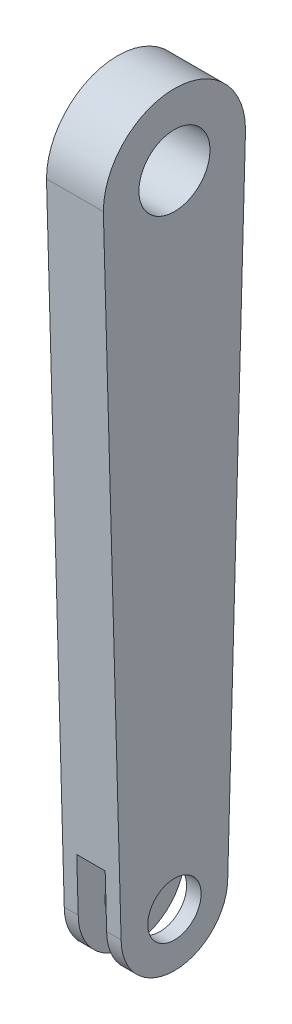
from build123d import *

# Parameters (mm, degrees)
EXTRUDE_1_DEPTH     = 16
SKETCH_2_R          = 10
SKETCH_2_R_2        = 7.5
CUT_EXTRUDE_1_DEPTH = 16
SKETCH_3_W          = 8
SKETCH_3_H          = 40
CUT_EXTRUDE_2_DEPTH = 65


with BuildPart() as part:
    # 草图1 → 凸台-拉伸1 (new body)
    with BuildSketch(Plane(origin=(0, 0, 0), x_dir=(0, 0, -1), z_dir=(1, 0, 0))):
        with BuildLine():
            ThreePointArc((20, 0), (0, 20), (-20, 0))
            Line((-20, 0), (-15, -180))
            ThreePointArc((-15, -180), (0, -195), (15, -180))
            Line((15, -180), (20, 0))
        make_face()
    extrude(amount=EXTRUDE_1_DEPTH)

    # 草图2 → 切除-拉伸1 (cut)
    with BuildSketch(Plane(origin=(16, 0, 0), x_dir=(0, 0, -1), z_dir=(1, 0, 0))):
        Circle(SKETCH_2_R)
        with Locations((0, -180)):
            Circle(SKETCH_2_R_2)
    extrude(amount=-CUT_EXTRUDE_1_DEPTH, mode=Mode.SUBTRACT)

    # 草图3 → 切除-拉伸2 (cut)
    with BuildSketch(Plane(origin=(0, -230, 0), x_dir=(1, 0, 0), z_dir=(0, 1, 0))):
        with Locations((7.927431522, 0)):
            Rectangle(SKETCH_3_W, SKETCH_3_H)
    extrude(amount=CUT_EXTRUDE_2_DEPTH, mode=Mode.SUBTRACT)


solid = part.part
